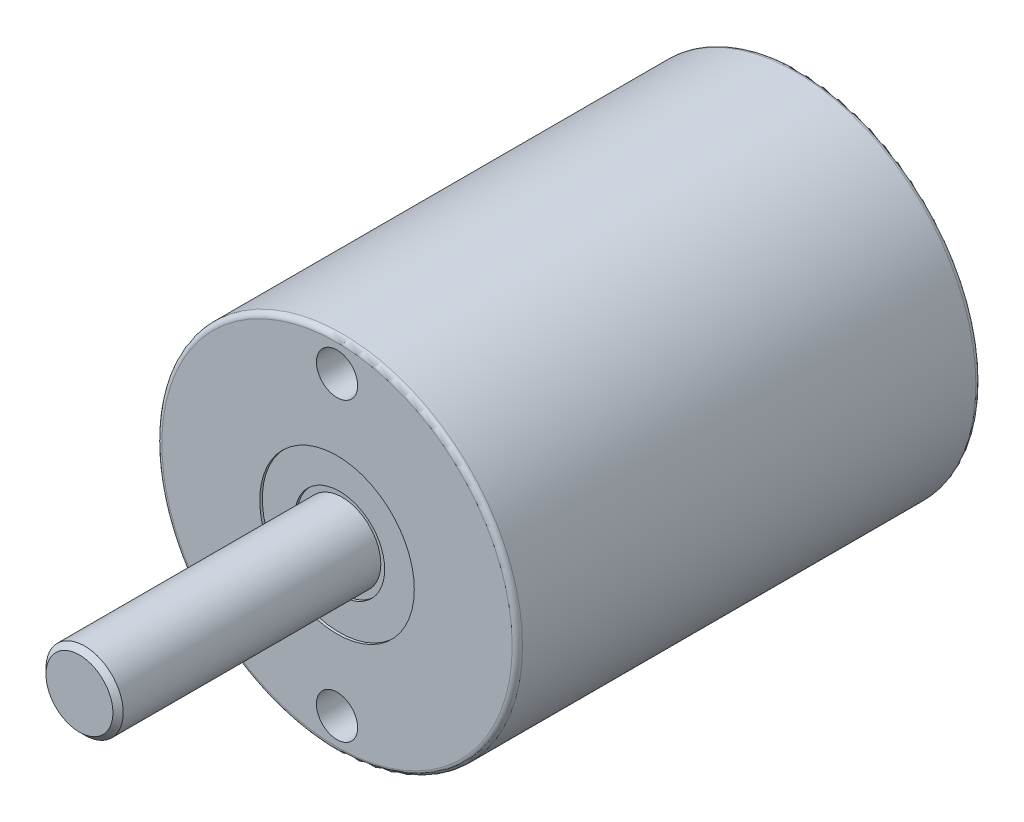
from build123d import *

# Parameters (mm, degrees)
SKETCH_1_R             = 7
EXTRUDE_1_DEPTH        = 18
FILLET_1_R             = 0.2
SKETCH_2_R             = 1.5
EXTRUDE_2_DEPTH        = 10
CHAMFER_1_SIZE         = 0.2
HOLE_WIZARD_M2_1_D     = 1.6
HOLE_WIZARD_M2_1_DEPTH = 6
HOLE_WIZARD_M2_1_TIP   = 0.480688495
SKETCH_6_R             = 1.75
SKETCH_6_R_2           = 1.5
CUT_EXTRUDE_1_DEPTH    = 0.2
SKETCH_7_R             = 3
SKETCH_7_R_2           = 1.75
CUT_EXTRUDE_2_DEPTH    = 0.1


with BuildPart() as part:
    # 草图1 → 凸台-拉伸1 (new body)
    with BuildSketch(Plane.XY):
        Circle(SKETCH_1_R)
    extrude(amount=EXTRUDE_1_DEPTH)

    # 圆角1
    fillet_1_edges = [part.edges().sort_by_distance(p)[0] for p in [
        (-7, 0, 0),
        (-7, 0, 18),
    ]]
    fillet(fillet_1_edges, radius=FILLET_1_R)

    # 草图2 → 凸台-拉伸2 (add)
    with BuildSketch(Plane.XY.offset(18)):
        Circle(SKETCH_2_R)
    extrude(amount=EXTRUDE_2_DEPTH)

    # 倒角1
    chamfer_1_edges = [part.edges().sort_by_distance(p)[0] for p in [
        (-1.5, 0, 28),
    ]]
    chamfer(chamfer_1_edges, length=CHAMFER_1_SIZE)

    # M2 螺纹孔1
    with Locations(Plane(origin=(0, 5.75, 18), x_dir=(1, 0, 0), z_dir=(0, 0, 1))):
        with Locations((0, 0), (0, -11.5)):
            Hole(HOLE_WIZARD_M2_1_D / 2, depth=HOLE_WIZARD_M2_1_DEPTH)
            with Locations((0, 0, -(HOLE_WIZARD_M2_1_DEPTH + HOLE_WIZARD_M2_1_TIP / 2))):  # 118° drill point
                Cone(0, HOLE_WIZARD_M2_1_D / 2, HOLE_WIZARD_M2_1_TIP, mode=Mode.SUBTRACT)

    # 草图6 → 切除-拉伸1 (cut)
    with BuildSketch(Plane.XY.offset(18)):
        Circle(SKETCH_6_R)
        Circle(SKETCH_6_R_2, mode=Mode.SUBTRACT)
    extrude(amount=-CUT_EXTRUDE_1_DEPTH, mode=Mode.SUBTRACT)

    # 草图7 → 切除-拉伸2 (cut)
    with BuildSketch(Plane.XY.offset(18)):
        Circle(SKETCH_7_R)
        Circle(SKETCH_7_R_2, mode=Mode.SUBTRACT)
    extrude(amount=-CUT_EXTRUDE_2_DEPTH, mode=Mode.SUBTRACT)


solid = part.part
